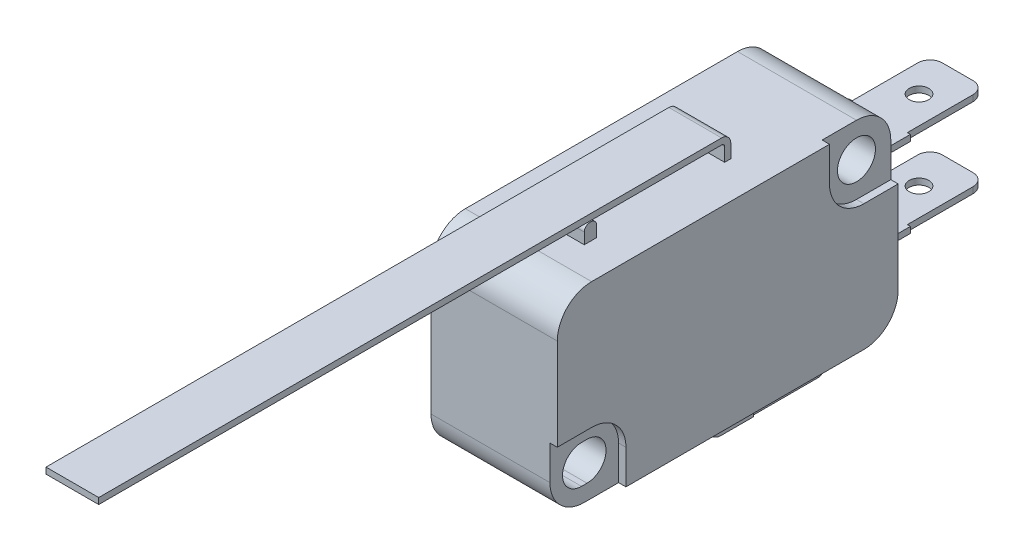
from build123d import *

# Parameters (mm, degrees)
SKETCH1_W           = 27.8
SKETCH1_H           = 15.9
BOSS_EXTRUDE1_DEPTH = 5.15
SKETCH4_R           = 1.55
CUT_EXTRUDE1_DEPTH  = 11.3
CUT_EXTRUDE2_DEPTH  = 0.6
SKETCH8_R           = 0.8
BOSS_EXTRUDE2_DEPTH = 0.25
LPATTERN1_COUNT     = 2
LPATTERN1_PITCH     = 6.5
BOSS_EXTRUDE3_DEPTH = 5
SKETCH10_W          = 4.75
SKETCH10_H          = 0.5
BOSS_EXTRUDE4_DEPTH = 6.35
CUT_EXTRUDE3_REACH  = 20.8
SKETCH11_R          = 0.8
BOSS_EXTRUDE5_DEPTH = 2.15
BOSS_EXTRUDE7_DEPTH = 2.25
FILLET1_R           = 2.8
FILLET2_R           = 1


with BuildPart() as part:
    # Sketch1 → Boss-Extrude1 (new body, symmetric)
    with BuildSketch(Plane(origin=(0, 0, 0), x_dir=(0, 0, -1), z_dir=(1, 0, 0))):
        Rectangle(SKETCH1_W, SKETCH1_H)
    extrude(amount=BOSS_EXTRUDE1_DEPTH, both=True)

    # Sketch4 → Cut-Extrude1 (cut, through all)
    with BuildSketch(Plane(origin=(5.15, 0, 0), x_dir=(0, 0, -1), z_dir=(1, 0, 0))):
        with Locations((11.1, 5.15)):
            Circle(SKETCH4_R)
        with BuildLine():
            Line((-11.325, -3.6), (-10.875, -3.6))
            ThreePointArc((-10.875, -3.6), (-9.325, -5.15), (-10.875, -6.7))
            Line((-10.875, -6.7), (-11.325, -6.7))
            ThreePointArc((-11.325, -6.7), (-12.875, -5.15), (-11.325, -3.6))
        make_face()
    extrude(amount=-CUT_EXTRUDE1_DEPTH, mode=Mode.SUBTRACT)

    # Sketch5 → Cut-Extrude2 (cut)
    with BuildSketch(Plane(origin=(5.15, 0, 0), x_dir=(0, 0, -1), z_dir=(1, 0, 0))):
        with BuildLine():
            Line((13.9, 2.35), (11.1, 2.35))
            ThreePointArc((11.1, 2.35), (9.120101013, 3.170101013), (8.3, 5.15))
            Line((8.3, 5.15), (8.3, 7.95))
            Line((8.3, 7.95), (13.9, 7.95))
            Line((13.9, 7.95), (13.9, 2.35))
        make_face()
        with BuildLine():
            Line((-13.9, -2.35), (-11.1, -2.35))
            ThreePointArc((-11.1, -2.35), (-9.120101013, -3.170101013), (-8.3, -5.15))
            Line((-8.3, -5.15), (-8.3, -7.95))
            Line((-8.3, -7.95), (-13.9, -7.95))
            Line((-13.9, -7.95), (-13.9, -2.35))
        make_face()
    extrude(amount=-CUT_EXTRUDE2_DEPTH, mode=Mode.SUBTRACT)

    # Sketch8 → Boss-Extrude2 (add, symmetric)
    with BuildSketch(Plane(origin=(0, 2.45, 0), x_dir=(1, 0, 0), z_dir=(0, 1, 0))):
        Polygon((-2.5, 13.9), (2.5, 13.9), (2.5, 17.55), (2.25, 17.55), (2.25, 23.9), (-2.25, 23.9), (-2.25, 17.55), (-2.5, 17.55), align=None)
        with Locations((0, 20.75)):
            Circle(SKETCH8_R, mode=Mode.SUBTRACT)
    boss_extrude2 = extrude(amount=BOSS_EXTRUDE2_DEPTH, both=True)

    # LPattern1: Boss-Extrude2 ×2
    with Locations(*[(0, -i * LPATTERN1_PITCH, 0) for i in range(1, LPATTERN1_COUNT)]):
        add(boss_extrude2)

    # Sketch9 → Boss-Extrude3 (add)
    with BuildSketch(Plane(origin=(2.5, 0, 0), x_dir=(0, 0, -1), z_dir=(1, 0, 0))):
        with BuildLine():
            Line((1.1, -7.95), (1.1, -9.85))
            ThreePointArc((1.1, -9.85), (1.392893219, -10.557106781), (2.1, -10.85))
            Line((2.1, -10.85), (4.75, -10.85))
            Line((4.75, -10.85), (4.75, -10.35))
            Line((4.75, -10.35), (2.1, -10.35))
            ThreePointArc((2.1, -10.35), (1.746446609, -10.203553391), (1.6, -9.85))
            Line((1.6, -9.85), (1.6, -7.95))
            Line((1.6, -7.95), (1.1, -7.95))
        make_face()
    extrude(amount=-BOSS_EXTRUDE3_DEPTH)

    # Sketch10 → Boss-Extrude4 (add)
    with BuildSketch(Plane(origin=(0, 0, -4.75), x_dir=(-1, 0, 0), z_dir=(0, 0, -1))):
        with Locations((0, -10.6)):
            Rectangle(SKETCH10_W, SKETCH10_H)
    extrude(amount=BOSS_EXTRUDE4_DEPTH)

    # Sketch11 → Cut-Extrude3 (cut, up to next)
    with BuildSketch(Plane.XZ.offset(10.85), mode=Mode.PRIVATE) as cut_extrude3_sk1:
        with Locations((0, -7.95)):
            Circle(SKETCH11_R)
    cut_extrude3_tool1 = extrude(cut_extrude3_sk1.sketch, amount=-CUT_EXTRUDE3_REACH, mode=Mode.PRIVATE) & part.part
    add(cut_extrude3_tool1.solids().sort_by_distance((0, -10.85, -7.95))[0], mode=Mode.SUBTRACT)

    # Sketch12 → Boss-Extrude5 (add, symmetric)
    with BuildSketch(Plane(origin=(0, 0, 0), x_dir=(0, 0, -1), z_dir=(1, 0, 0))):
        with BuildLine():
            Line((3.25, 7.95), (3.25, 9.05))
            ThreePointArc((3.25, 9.05), (3.030330086, 9.580330086), (2.5, 9.8))
            Line((2.5, 9.8), (-48.3, 9.8))
            Line((-48.3, 9.8), (-48.3, 9.3))
            Line((-48.3, 9.3), (2.5, 9.3))
            ThreePointArc((2.5, 9.3), (2.676776695, 9.226776695), (2.75, 9.05))
            Line((2.75, 9.05), (2.75, 7.95))
            Line((2.75, 7.95), (3.25, 7.95))
        make_face()
    extrude(amount=BOSS_EXTRUDE5_DEPTH, both=True)

    # Sketch13 → Boss-Extrude7 (add, symmetric)
    with BuildSketch(Plane(origin=(0, 0, 0), x_dir=(0, 0, -1), z_dir=(1, 0, 0))):
        with BuildLine():
            Line((-8.8, 8.85), (-8.8, 7.95))
            Line((-8.8, 7.95), (-7.8, 7.95))
            Line((-7.8, 7.95), (-7.8, 8.85))
            ThreePointArc((-7.8, 8.85), (-7.931801948, 9.168198052), (-8.25, 9.3))
            Line((-8.25, 9.3), (-8.35, 9.3))
            ThreePointArc((-8.35, 9.3), (-8.668198052, 9.168198052), (-8.8, 8.85))
        make_face()
    extrude(amount=BOSS_EXTRUDE7_DEPTH, both=True)

    # Fillet1
    fillet1_edges = [part.edges().sort_by_distance(p)[0] for p in [
        (-0.3, 7.95, -13.9),
        (-0.3, -7.95, 13.9),
        (0, -7.95, -13.9),
        (0, 7.95, 13.9),
    ]]
    fillet(fillet1_edges, radius=FILLET1_R)

    # Fillet2
    fillet2_edges = [part.edges().sort_by_distance(p)[0] for p in [
        (2.375, -10.6, -11.1),
        (-2.375, -10.6, -11.1),
        (2.25, -4.05, -23.9),
        (-2.25, -4.05, -23.9),
        (-2.25, 2.45, -23.9),
        (2.25, 2.45, -23.9),
    ]]
    fillet(fillet2_edges, radius=FILLET2_R)


solid = part.part
